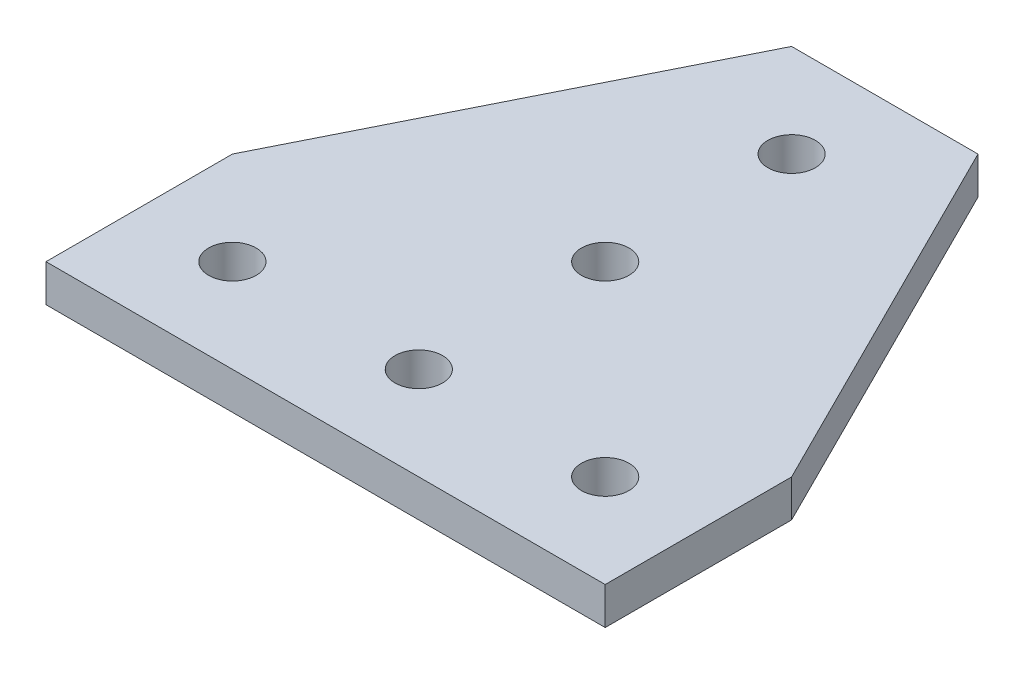
from build123d import *

# Parameters (mm, degrees)
SKETCH1_R           = 2.55
BOSS_EXTRUDE1_DEPTH = 4


with BuildPart() as part:
    # Sketch1 → Boss-Extrude1 (new body)
    with BuildSketch(Plane(origin=(0, 0, 0), x_dir=(1, 0, 0), z_dir=(0, 1, 0))):
        Polygon((30, -10), (-30, -10), (-30, 10), (-10, 50), (10, 50), (30, 10), align=None)
        with Locations((-20, 0)):
            Circle(SKETCH1_R, mode=Mode.SUBTRACT)
        with Locations((20, 0)):
            Circle(SKETCH1_R, mode=Mode.SUBTRACT)
        Circle(SKETCH1_R, mode=Mode.SUBTRACT)
        with Locations((0, 20)):
            Circle(SKETCH1_R, mode=Mode.SUBTRACT)
        with Locations((0, 40)):
            Circle(SKETCH1_R, mode=Mode.SUBTRACT)
    extrude(amount=BOSS_EXTRUDE1_DEPTH)


solid = part.part
